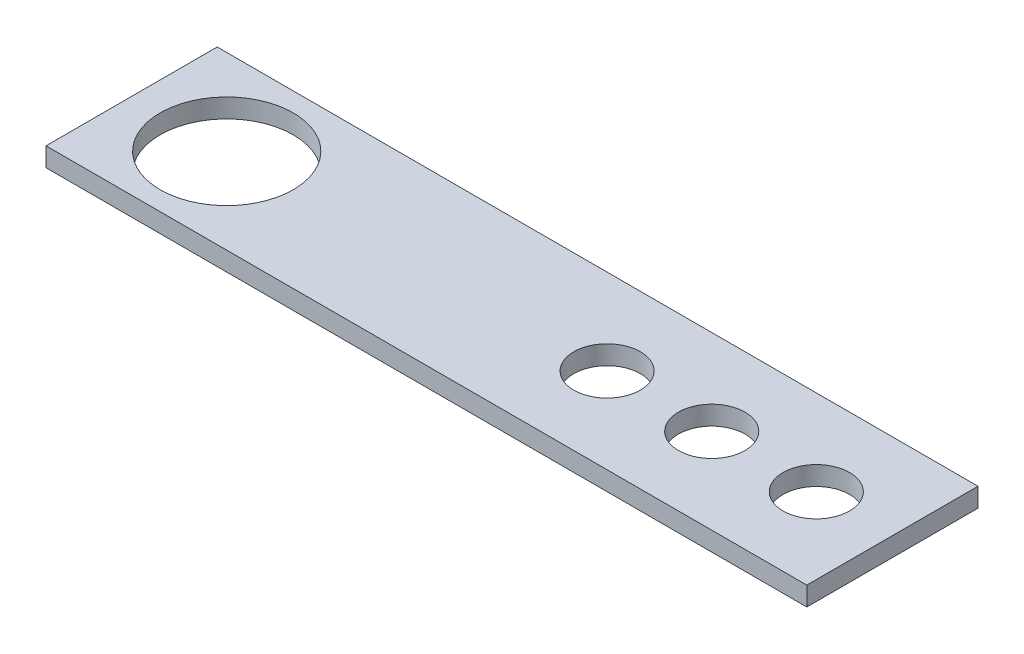
from build123d import *

# Parameters (mm, degrees)
SKETCH2_W           = 40
SKETCH2_H           = 9
BOSS_EXTRUDE1_DEPTH = 1
SKETCH3_R           = 3.5
CUT_EXTRUDE1_DEPTH  = 3
SKETCH4_R           = 1.75
CUT_EXTRUDE2_DEPTH  = 3
LPATTERN1_COUNT     = 3
LPATTERN1_PITCH     = 5.5


with BuildPart() as part:
    # Sketch2 → Boss-Extrude1 (new body)
    with BuildSketch(Plane(origin=(0, 0, 0), x_dir=(1, 0, 0), z_dir=(0, 1, 0))):
        Rectangle(SKETCH2_W, SKETCH2_H)
    extrude(amount=BOSS_EXTRUDE1_DEPTH)

    # Sketch3 → Cut-Extrude1 (cut)
    with BuildSketch(Plane(origin=(0, 1, 0), x_dir=(1, 0, 0), z_dir=(0, 1, 0))):
        with Locations((-15, 0)):
            Circle(SKETCH3_R)
    extrude(amount=-CUT_EXTRUDE1_DEPTH, mode=Mode.SUBTRACT)

    # Sketch4 → Cut-Extrude2 (cut)
    with BuildSketch(Plane(origin=(0, 1, 0), x_dir=(1, 0, 0), z_dir=(0, 1, 0))):
        with Locations((5, 0)):
            Circle(SKETCH4_R)
    cut_extrude2 = extrude(amount=-CUT_EXTRUDE2_DEPTH, mode=Mode.SUBTRACT)

    # LPattern1: Cut-Extrude2 ×3
    with Locations(*[(i * LPATTERN1_PITCH, 0, 0) for i in range(1, LPATTERN1_COUNT)]):
        add(cut_extrude2, mode=Mode.SUBTRACT)


solid = part.part
